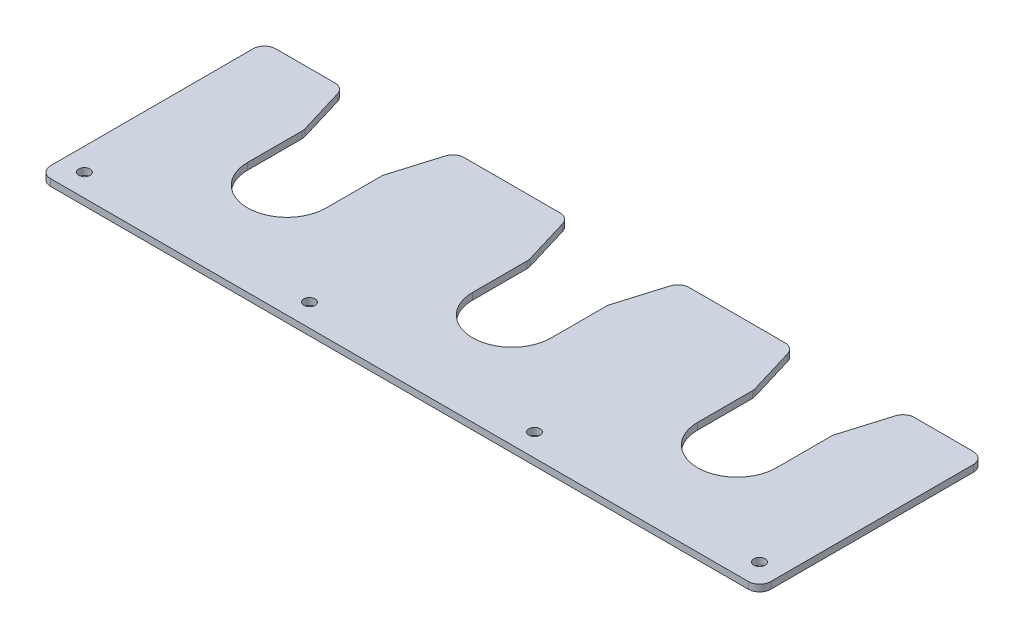
from build123d import *

# Parameters (mm, degrees)
SKETCH1_W              = 320
SKETCH1_H              = 100
BOSS_EXTRUDE1_DEPTH    = 3
SKETCH2_R              = 2.5
CUT_EXTRUDE1_DEPTH     = 4
LPATTERN1_COUNT        = 4
LPATTERN1_PITCH        = 100
CUT_EXTRUDE2_DEPTH     = 4
FILLET1_R              = 5
LPATTERN2_COUNT        = 3
LPATTERN2_PITCH        = 100
FILLET1_OF_LPATTERN2_R = 5
FILLET2_R              = 5


with BuildPart() as part:
    # Sketch1 → Boss-Extrude1 (new body)
    with BuildSketch(Plane(origin=(0, 0, 0), x_dir=(1, 0, 0), z_dir=(0, 1, 0))):
        with Locations((0, 50)):
            Rectangle(SKETCH1_W, SKETCH1_H)
    extrude(amount=BOSS_EXTRUDE1_DEPTH)

    # Sketch2 → Cut-Extrude1 (cut, through all)
    with BuildSketch(Plane(origin=(0, 3, 0), x_dir=(1, 0, 0), z_dir=(0, 1, 0))):
        with Locations((-150, 10)):
            Circle(SKETCH2_R)
    cut_extrude1 = extrude(amount=-CUT_EXTRUDE1_DEPTH, mode=Mode.SUBTRACT)

    # LPattern1: Cut-Extrude1 ×4
    with Locations(*[(i * LPATTERN1_PITCH, 0, 0) for i in range(1, LPATTERN1_COUNT)]):
        add(cut_extrude1, mode=Mode.SUBTRACT)

    # Sketch3 → Cut-Extrude2 (cut, through all)
    with BuildSketch(Plane(origin=(0, 3, 0), x_dir=(1, 0, 0), z_dir=(0, 1, 0))):
        with BuildLine():
            Line((-125, 100), (-117.5, 75))
            Line((-117.5, 75), (-117.5, 50))
            ThreePointArc((-117.5, 50), (-100, 32.5), (-82.5, 50))
            Line((-82.5, 50), (-82.5, 75))
            Line((-82.5, 75), (-75, 100))
            Line((-75, 100), (-125, 100))
        make_face()
    cut_extrude2 = extrude(amount=-CUT_EXTRUDE2_DEPTH, mode=Mode.SUBTRACT)

    # Fillet1
    fillet1_edges = [part.edges().sort_by_distance(p)[0] for p in [
        (-125, 1.5, -100),
        (-75, 1.5, -100),
        (-82.5, 1.5, -75),
        (-117.5, 1.5, -75),
    ]]
    fillet(fillet1_edges, radius=FILLET1_R)

    # LPattern2: Cut-Extrude2 ×3
    with Locations(*[(i * LPATTERN2_PITCH, 0, 0) for i in range(1, LPATTERN2_COUNT)]):
        add(cut_extrude2, mode=Mode.SUBTRACT)

    # Fillet1 of LPattern2
    fillet1_of_lpattern2_edges = [part.edges().sort_by_distance(p)[0] for p in [
        (-25, 1.5, -100),
        (25, 1.5, -100),
        (17.5, 1.5, -75),
        (-17.5, 1.5, -75),
        (75, 1.5, -100),
        (125, 1.5, -100),
        (117.5, 1.5, -75),
        (82.5, 1.5, -75),
    ]]
    fillet(fillet1_of_lpattern2_edges, radius=FILLET1_OF_LPATTERN2_R)

    # Fillet2
    fillet2_edges = [part.edges().sort_by_distance(p)[0] for p in [
        (-160, 1.5, -100),
        (160, 1.5, -100),
        (160, 1.5, 0),
        (-160, 1.5, 0),
    ]]
    fillet(fillet2_edges, radius=FILLET2_R)


solid = part.part
